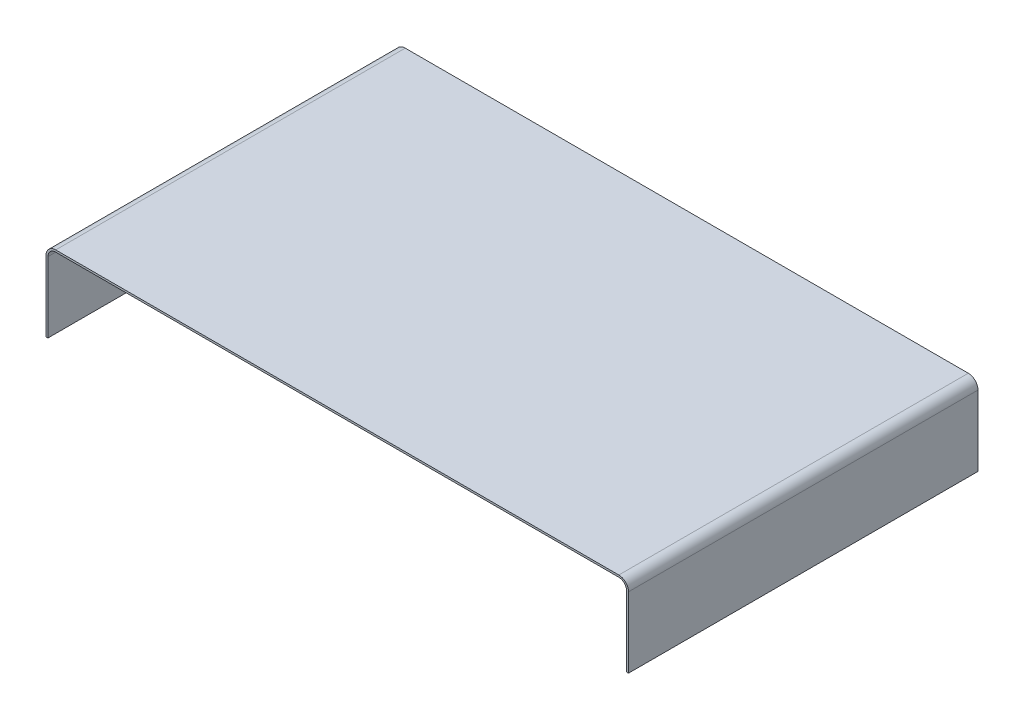
from build123d import *

# Parameters (mm, degrees)
RESSALTO_EXTRUS_O1_DEPTH = 180


with BuildPart() as part:
    # Esboço1 → Ressalto-extrusão1 (new body)
    with BuildSketch(Plane.XY):
        with BuildLine():
            Line((0, 0), (0, 36.3))
            ThreePointArc((0, 36.3), (1.464466094, 39.835533906), (5, 41.3))
            Line((5, 41.3), (295, 41.3))
            ThreePointArc((295, 41.3), (298.535533906, 39.835533906), (300, 36.3))
            Line((300, 36.3), (300, 0))
            Line((300, 0), (299, 0))
            Line((299, 0), (299, 36.3))
            ThreePointArc((299, 36.3), (297.828427125, 39.128427125), (295, 40.3))
            Line((295, 40.3), (5, 40.3))
            ThreePointArc((5, 40.3), (2.171572875, 39.128427125), (1, 36.3))
            Line((1, 36.3), (1, 0))
            Line((1, 0), (0, 0))
        make_face()
    extrude(amount=RESSALTO_EXTRUS_O1_DEPTH)


solid = part.part
